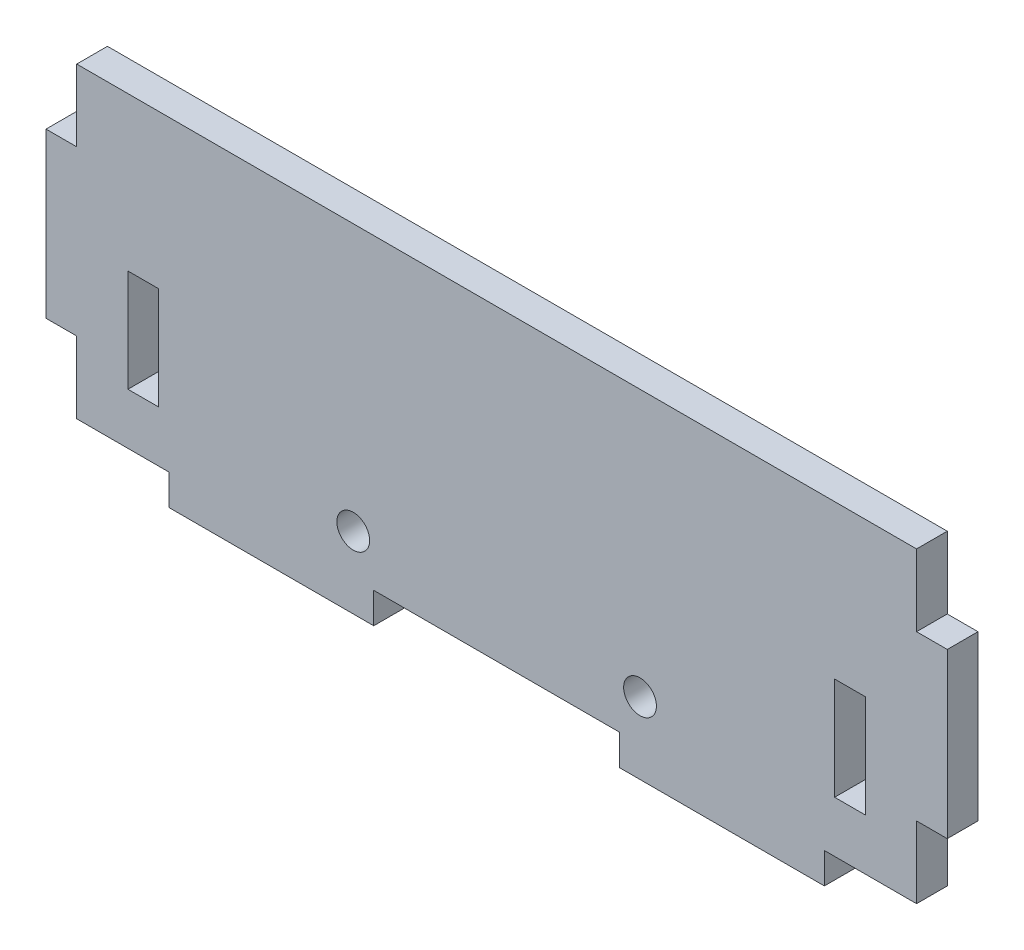
from build123d import *

# Parameters (mm, degrees)
SKETCH_1_R      = 1.6
SKETCH_1_W      = 3
SKETCH_1_H      = 10
EXTRUDE_1_DEPTH = 3


with BuildPart() as part:
    # 草图1 → 凸台-拉伸1 (new body)
    with BuildSketch(Plane.XY):
        Polygon((3, 0), (12, 0), (12, -3), (32, -3), (32, 0), (56, 0), (56, -3), (76, -3), (76, 0), (85, 0), (85, 7), (88, 7), (88, 23), (85, 23), (85, 30), (3, 30), (3, 23), (0, 23), (0, 7), (3, 7), align=None)
        with Locations((30, 4)):
            Circle(SKETCH_1_R, mode=Mode.SUBTRACT)
        with Locations((58, 4)):
            Circle(SKETCH_1_R, mode=Mode.SUBTRACT)
        with Locations((9.5, 10)):
            Rectangle(SKETCH_1_W, SKETCH_1_H, mode=Mode.SUBTRACT)
        with Locations((78.5, 10)):
            Rectangle(SKETCH_1_W, SKETCH_1_H, mode=Mode.SUBTRACT)
    extrude(amount=EXTRUDE_1_DEPTH)


solid = part.part
